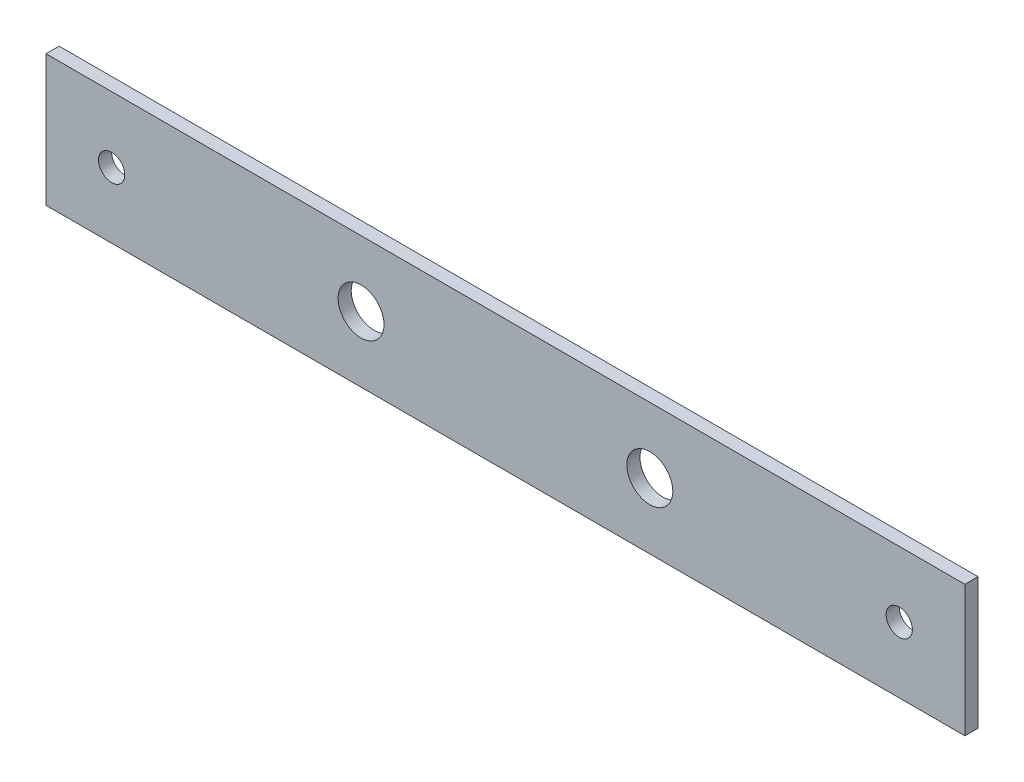
from build123d import *

# Parameters (mm, degrees)
SKETCH1_W           = 140
SKETCH1_H           = 20
BOSS_EXTRUDE1_DEPTH = 2
SKETCH2_R           = 2
CUT_EXTRUDE1_DEPTH  = 3
CUT_EXTRUDE2_REACH  = 4
SKETCH3_R           = 3.5


with BuildPart() as part:
    # Sketch1 → Boss-Extrude1 (new body)
    with BuildSketch(Plane.XY):
        Rectangle(SKETCH1_W, SKETCH1_H)
    extrude(amount=BOSS_EXTRUDE1_DEPTH)

    # Sketch2 → Cut-Extrude1 (cut, through all)
    with BuildSketch(Plane.XY.offset(2)):
        with Locations((-60, 0)):
            Circle(SKETCH2_R)
        with Locations((60, 0)):
            Circle(SKETCH2_R)
    extrude(amount=-CUT_EXTRUDE1_DEPTH, mode=Mode.SUBTRACT)

    # Sketch3 → Cut-Extrude2 (cut, up to next)
    with BuildSketch(Plane.XY.offset(2), mode=Mode.PRIVATE) as cut_extrude2_sk1:
        with Locations((22, 0)):
            Circle(SKETCH3_R)
    cut_extrude2_tool1 = extrude(cut_extrude2_sk1.sketch, amount=-CUT_EXTRUDE2_REACH, mode=Mode.PRIVATE) & part.part
    add(cut_extrude2_tool1.solids().sort_by_distance((22, 0, 2))[0], mode=Mode.SUBTRACT)
    # Sketch3 → Cut-Extrude2 (cut, up to next)
    with BuildSketch(Plane.XY.offset(2), mode=Mode.PRIVATE) as cut_extrude2_sk2:
        with Locations((-22, 0)):
            Circle(SKETCH3_R)
    cut_extrude2_tool2 = extrude(cut_extrude2_sk2.sketch, amount=-CUT_EXTRUDE2_REACH, mode=Mode.PRIVATE) & part.part
    add(cut_extrude2_tool2.solids().sort_by_distance((-22, 0, 2))[0], mode=Mode.SUBTRACT)


solid = part.part
